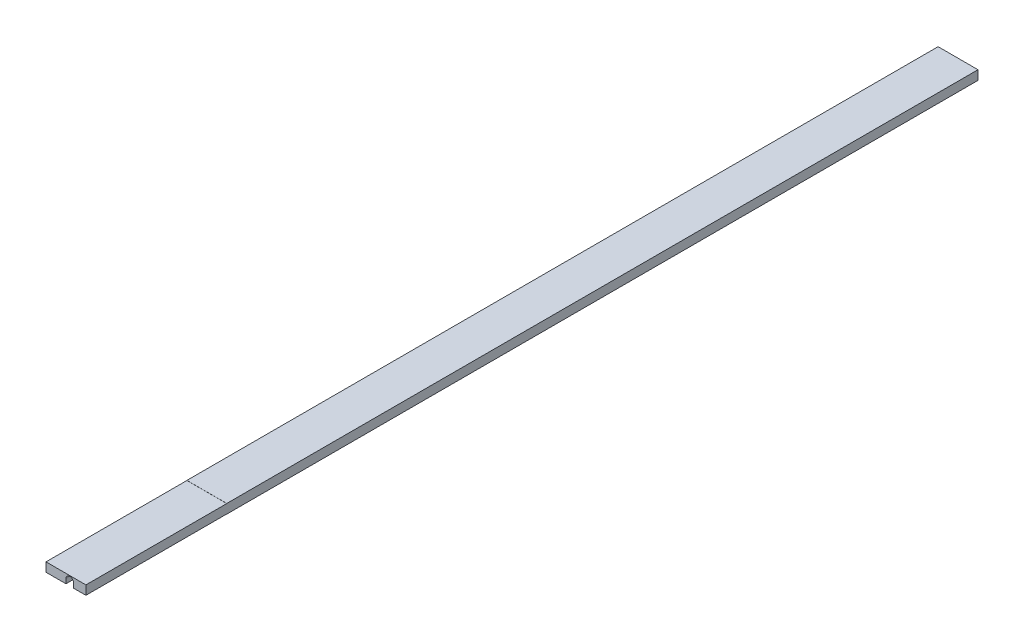
from build123d import *

# Parameters (mm, degrees)
SKETCH1_W           = 25
SKETCH1_H           = 5.8
EXTRUDE1_DEPTH      = 259.4
SKETCH6_W           = 25
SKETCH6_H           = 20
BOSS_EXTRUDE2_DEPTH = 5.8
CUT_EXTRUDE2_DEPTH  = 559.8
SKETCH8_W           = 88.25
SKETCH8_H           = 0.06858
CUT_EXTRUDE3_DEPTH  = 26


with BuildPart() as part:
    # Sketch1 → Extrude1 (new body, symmetric)
    with BuildSketch(Plane.XY):
        Rectangle(SKETCH1_W, SKETCH1_H)
    extrude(amount=EXTRUDE1_DEPTH, both=True)

    # Sketch6 → Boss-Extrude2 (add)
    with BuildSketch(Plane(origin=(0, 2.9, 0), x_dir=(1, 0, 0), z_dir=(0, 1, 0))):
        with Locations((0, 269.4)):
            Rectangle(SKETCH6_W, SKETCH6_H)
        with Locations((0, -269.4)):
            Rectangle(SKETCH6_W, SKETCH6_H)
    extrude(amount=-BOSS_EXTRUDE2_DEPTH)

    # Sketch7 → Cut-Extrude2 (cut, through all)
    with BuildSketch(Plane.XY.offset(279.4)):
        with BuildLine():
            Line((-0.00025, 0.0222), (-0.00025, -2.9))
            Line((-0.00025, -2.9), (4.76225, -2.9))
            Line((4.76225, -2.9), (4.76225, 0.0222))
            ThreePointArc((4.76225, 0.0222), (2.381, 2.40345), (-0.00025, 0.0222))
        make_face()
    extrude(amount=-CUT_EXTRUDE2_DEPTH, mode=Mode.SUBTRACT)

    # Sketch8 → Cut-Extrude3 (cut, through all)
    with BuildSketch(Plane.ZY.offset(12.5)):
        with Locations((235.275, 2.86571)):
            Rectangle(SKETCH8_W, SKETCH8_H)
        with Locations((235.275, -2.86571)):
            Rectangle(SKETCH8_W, SKETCH8_H)
    extrude(amount=-CUT_EXTRUDE3_DEPTH, mode=Mode.SUBTRACT)


solid = part.part
